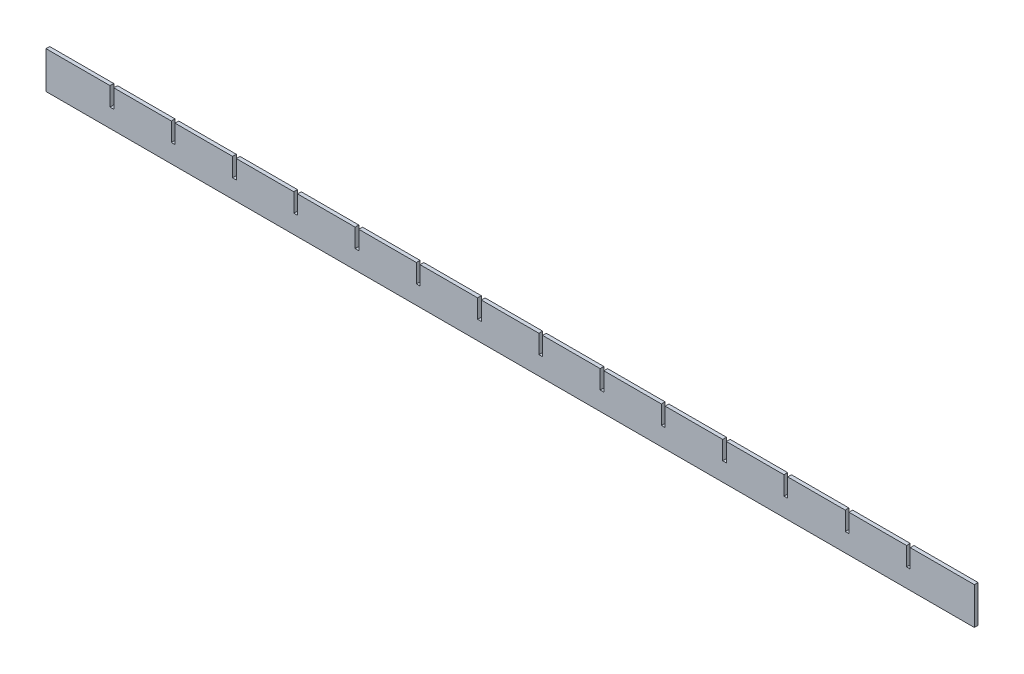
from build123d import *

# Parameters (mm, degrees)
ESQUISSE1_W                = 500
ESQUISSE1_H                = 20
BOSS_EXTRU_1_DEPTH         = 1
ESQUISSE2_W                = 2
ESQUISSE2_H                = 10
ENL_V_MAT_EXTRU_1_DEPTH    = 3
R_P_TITION_LIN_AIRE1_COUNT = 7
R_P_TITION_LIN_AIRE1_PITCH = 33
SYM_TRIE1_COPY_1_SKETCH_W  = 2
SYM_TRIE1_COPY_1_SKETCH_H  = 10
SYM_TRIE1_COPY_1_DEPTH     = 3
SYM_TRIE1_COPY_2_SKETCH_W  = 2
SYM_TRIE1_COPY_2_SKETCH_H  = 10
SYM_TRIE1_COPY_2_DEPTH     = 3
SYM_TRIE1_COPY_3_SKETCH_W  = 2
SYM_TRIE1_COPY_3_SKETCH_H  = 10
SYM_TRIE1_COPY_3_DEPTH     = 3
SYM_TRIE1_COPY_4_SKETCH_W  = 2
SYM_TRIE1_COPY_4_SKETCH_H  = 10
SYM_TRIE1_COPY_4_DEPTH     = 3
SYM_TRIE1_COPY_5_SKETCH_W  = 2
SYM_TRIE1_COPY_5_SKETCH_H  = 10
SYM_TRIE1_COPY_5_DEPTH     = 3
SYM_TRIE1_COPY_6_SKETCH_W  = 2
SYM_TRIE1_COPY_6_SKETCH_H  = 10
SYM_TRIE1_COPY_6_DEPTH     = 3


with BuildPart() as part:
    # Esquisse1 → Boss.-Extru.1 (new body, symmetric)
    with BuildSketch(Plane.XY):
        Rectangle(ESQUISSE1_W, ESQUISSE1_H)
    extrude(amount=BOSS_EXTRU_1_DEPTH, both=True)

    # Esquisse2 → Enlèv. mat.-Extru.1 (cut, through all)
    with BuildSketch(Plane.XY.offset(1)):
        with Locations((16.5, 5)):
            Rectangle(ESQUISSE2_W, ESQUISSE2_H)
    enl_v_mat_extru_1 = extrude(amount=-ENL_V_MAT_EXTRU_1_DEPTH, mode=Mode.SUBTRACT)

    # Répétition linéaire1: Enlèv. mat.-Extru.1 ×7
    with Locations(*[(i * R_P_TITION_LIN_AIRE1_PITCH, 0, 0) for i in range(1, R_P_TITION_LIN_AIRE1_COUNT)]):
        add(enl_v_mat_extru_1, mode=Mode.SUBTRACT)

    # Symétrie1: Enlèv. mat.-Extru.1 across plane
    add(enl_v_mat_extru_1.mirror(Plane(origin=(0, 0, 0), x_dir=(0, 0, 1), z_dir=(1, 0, 0))), mode=Mode.SUBTRACT)

    # Symétrie1 copy 1 sketch → Symétrie1 copy 1 (cut, through all)
    with BuildSketch(Plane(origin=(-33, 0, 1), x_dir=(-1, 0, 0), z_dir=(0, 0, 1))):
        with Locations((16.5, -5)):
            Rectangle(SYM_TRIE1_COPY_1_SKETCH_W, SYM_TRIE1_COPY_1_SKETCH_H)
    extrude(amount=-SYM_TRIE1_COPY_1_DEPTH, mode=Mode.SUBTRACT)

    # Symétrie1 copy 2 sketch → Symétrie1 copy 2 (cut, through all)
    with BuildSketch(Plane(origin=(-66, 0, 1), x_dir=(-1, 0, 0), z_dir=(0, 0, 1))):
        with Locations((16.5, -5)):
            Rectangle(SYM_TRIE1_COPY_2_SKETCH_W, SYM_TRIE1_COPY_2_SKETCH_H)
    extrude(amount=-SYM_TRIE1_COPY_2_DEPTH, mode=Mode.SUBTRACT)

    # Symétrie1 copy 3 sketch → Symétrie1 copy 3 (cut, through all)
    with BuildSketch(Plane(origin=(-99, 0, 1), x_dir=(-1, 0, 0), z_dir=(0, 0, 1))):
        with Locations((16.5, -5)):
            Rectangle(SYM_TRIE1_COPY_3_SKETCH_W, SYM_TRIE1_COPY_3_SKETCH_H)
    extrude(amount=-SYM_TRIE1_COPY_3_DEPTH, mode=Mode.SUBTRACT)

    # Symétrie1 copy 4 sketch → Symétrie1 copy 4 (cut, through all)
    with BuildSketch(Plane(origin=(-132, 0, 1), x_dir=(-1, 0, 0), z_dir=(0, 0, 1))):
        with Locations((16.5, -5)):
            Rectangle(SYM_TRIE1_COPY_4_SKETCH_W, SYM_TRIE1_COPY_4_SKETCH_H)
    extrude(amount=-SYM_TRIE1_COPY_4_DEPTH, mode=Mode.SUBTRACT)

    # Symétrie1 copy 5 sketch → Symétrie1 copy 5 (cut, through all)
    with BuildSketch(Plane(origin=(-165, 0, 1), x_dir=(-1, 0, 0), z_dir=(0, 0, 1))):
        with Locations((16.5, -5)):
            Rectangle(SYM_TRIE1_COPY_5_SKETCH_W, SYM_TRIE1_COPY_5_SKETCH_H)
    extrude(amount=-SYM_TRIE1_COPY_5_DEPTH, mode=Mode.SUBTRACT)

    # Symétrie1 copy 6 sketch → Symétrie1 copy 6 (cut, through all)
    with BuildSketch(Plane(origin=(-198, 0, 1), x_dir=(-1, 0, 0), z_dir=(0, 0, 1))):
        with Locations((16.5, -5)):
            Rectangle(SYM_TRIE1_COPY_6_SKETCH_W, SYM_TRIE1_COPY_6_SKETCH_H)
    extrude(amount=-SYM_TRIE1_COPY_6_DEPTH, mode=Mode.SUBTRACT)


solid = part.part
